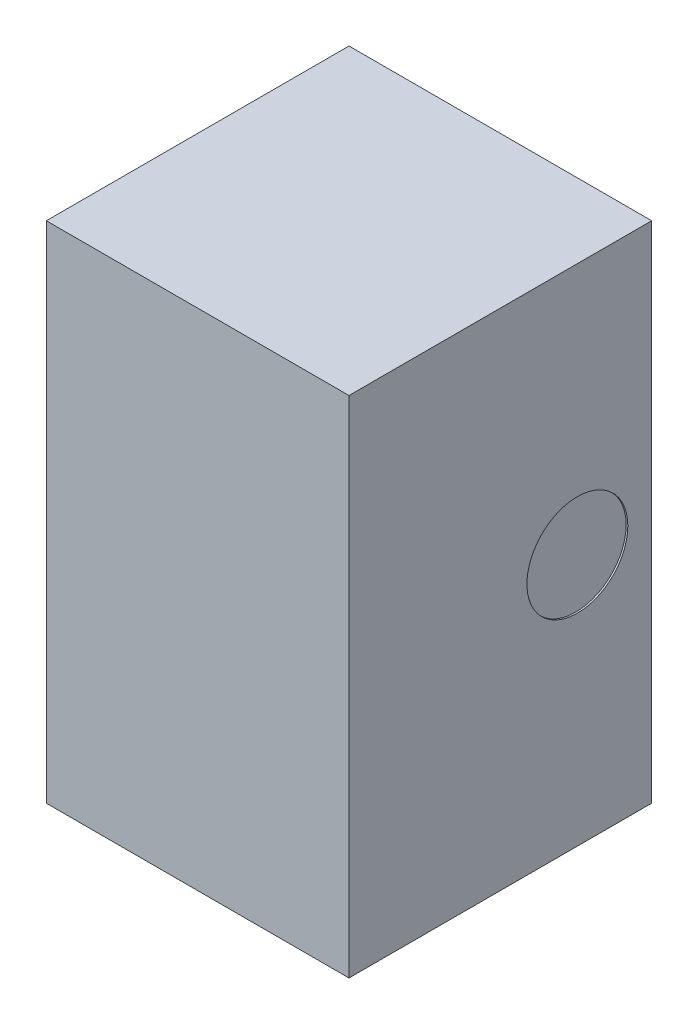
from build123d import *

# Parameters (mm, degrees)
SKETCH1_W           = 0.9
SKETCH1_H           = 0.9
BOSS_EXTRUDE1_DEPTH = 1.5
SKETCH2_R           = 0.15
CUT_EXTRUDE1_DEPTH  = 0.005


with BuildPart() as part:
    # Sketch1 → Boss-Extrude1 (new body)
    with BuildSketch(Plane(origin=(0, 0, 0), x_dir=(1, 0, 0), z_dir=(0, 1, 0))):
        Rectangle(SKETCH1_W, SKETCH1_H)
    extrude(amount=BOSS_EXTRUDE1_DEPTH)

    # Sketch2 → Cut-Extrude1 (cut)
    with BuildSketch(Plane(origin=(0.45, 0, 0), x_dir=(0, 0, -1), z_dir=(1, 0, 0))):
        with Locations((0.229047371, 0.75)):
            Circle(SKETCH2_R)
    extrude(amount=-CUT_EXTRUDE1_DEPTH, mode=Mode.SUBTRACT)


solid = part.part
